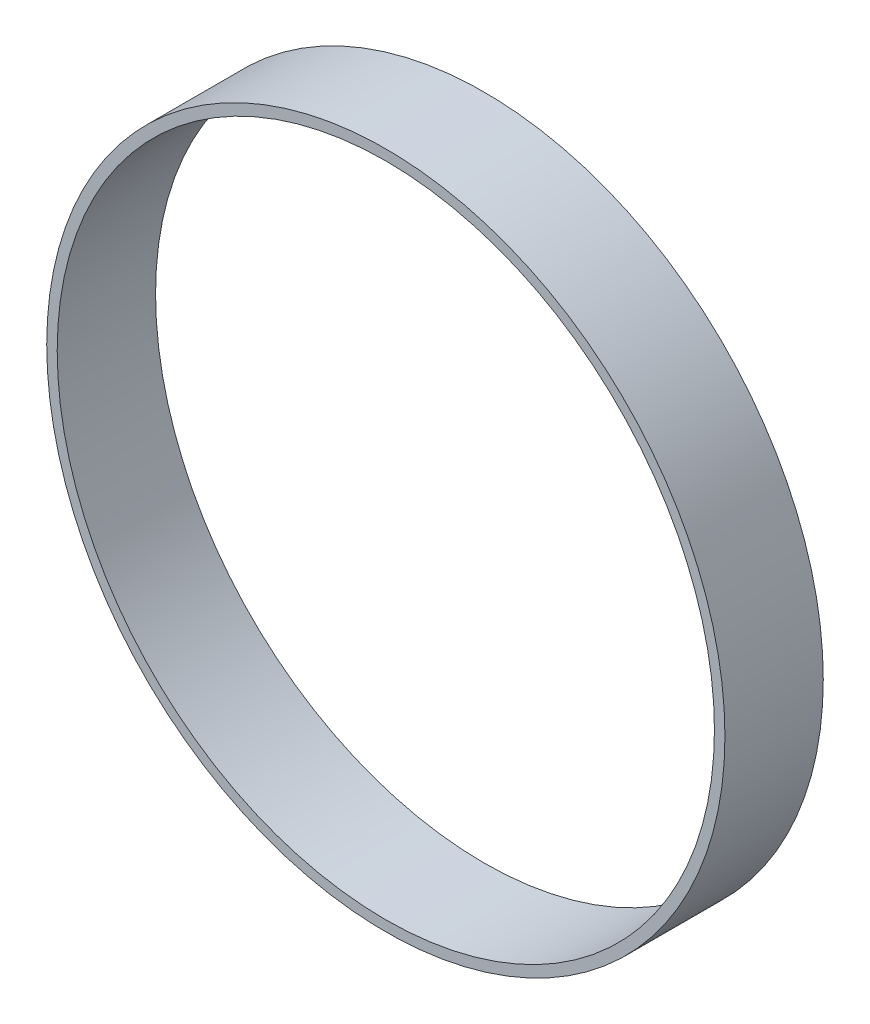
from build123d import *

# Parameters (mm, degrees)
SKETCH1_R           = 16.4211
SKETCH1_R_2         = 15.9131
BOSS_EXTRUDE1_DEPTH = 4.7625


with BuildPart() as part:
    # Sketch1 → Boss-Extrude1 (new body)
    with BuildSketch(Plane.XY):
        Circle(SKETCH1_R)
        Circle(SKETCH1_R_2, mode=Mode.SUBTRACT)
    extrude(amount=BOSS_EXTRUDE1_DEPTH)


solid = part.part
